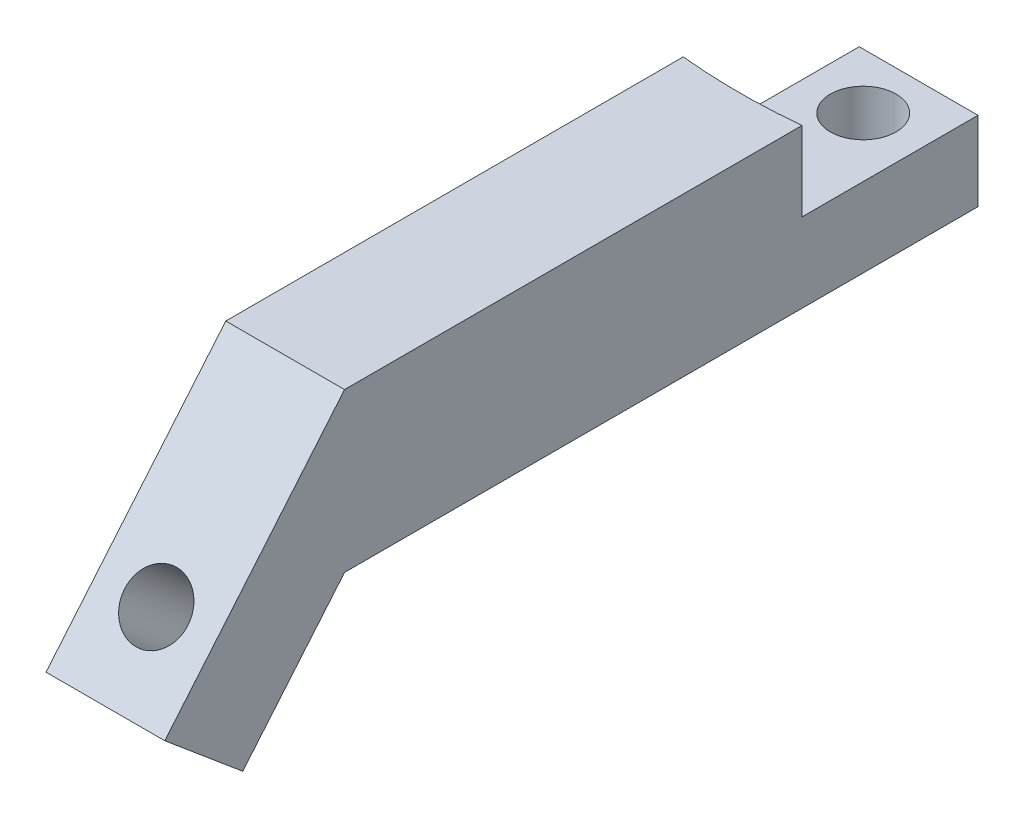
from build123d import *

# Parameters (mm, degrees)
SKETCH1_W           = 15
SKETCH1_H           = 80
SKETCH1_R           = 4.15
BOSS_EXTRUDE1_DEPTH = 10
BOSS_EXTRUDE2_DEPTH = 10
BOSS_EXTRUDE4_DEPTH = 15
SKETCH11_R          = 4
CUT_EXTRUDE5_DEPTH  = 31.247894791


with BuildPart() as part:
    # Sketch1 → Boss-Extrude1 (new body)
    with BuildSketch(Plane(origin=(0, 0, 0), x_dir=(1, 0, 0), z_dir=(0, 1, 0))):
        Rectangle(SKETCH1_W, SKETCH1_H)
        with Locations((0, 33)):
            Circle(SKETCH1_R, mode=Mode.SUBTRACT)
    extrude(amount=BOSS_EXTRUDE1_DEPTH)

    # Sketch2 → Boss-Extrude2 (add)
    with BuildSketch(Plane(origin=(0, 10, 0), x_dir=(1, 0, 0), z_dir=(0, 1, 0))):
        with BuildLine():
            Line((7.5, 17.775942217), (7.5, -40))
            Line((7.5, -40), (-7.5, -40))
            Line((-7.5, -40), (-7.5, 17.775942217))
            ThreePointArc((-7.5, 17.775942217), (0, 17.4), (7.5, 17.775942217))
        make_face()
    extrude(amount=BOSS_EXTRUDE2_DEPTH)

    # Sketch10 → Boss-Extrude4 (add)
    with BuildSketch(Plane(origin=(7.5, 0, 0), x_dir=(0, 0, -1), z_dir=(1, 0, 0))):
        Polygon((-40, 0), (-52.855752194, -15.320888862), (-62.703829724, -7.057370639), (-40, 20), align=None)
    extrude(amount=-BOSS_EXTRUDE4_DEPTH)

    # Sketch11 → Cut-Extrude5 (cut, through all)
    with BuildSketch(Plane(origin=(0, 19.69615506, 23.472963553), x_dir=(-1, 0, 0), z_dir=(0, -0.64278761, -0.766044443))):
        with Locations((0, -35.711504387)):
            Circle(SKETCH11_R)
    extrude(amount=-CUT_EXTRUDE5_DEPTH, mode=Mode.SUBTRACT)


solid = part.part
